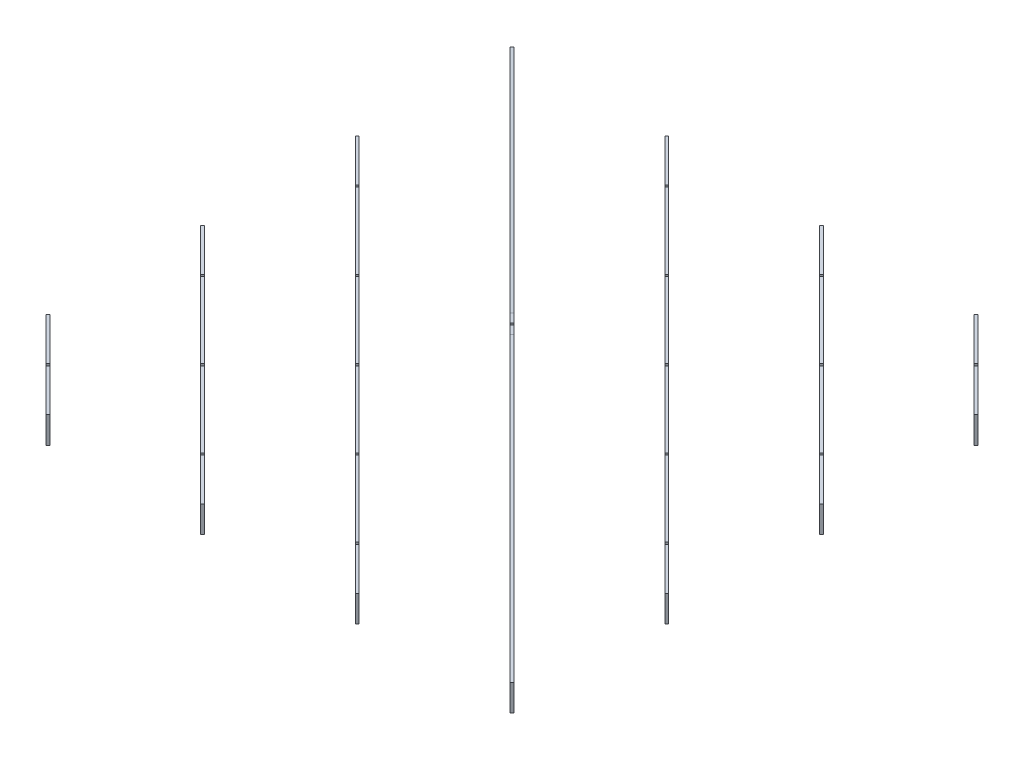
from build123d import *

# Parameters (mm, degrees)
BOSS_EXTRUDE1_DEPTH   = 60
BOSS_EXTRUDE1_2_DEPTH = 60
BOSS_EXTRUDE1_3_DEPTH = 60
BOSS_EXTRUDE1_4_DEPTH = 60
BOSS_EXTRUDE1_5_DEPTH = 60
BOSS_EXTRUDE1_6_DEPTH = 60
BOSS_EXTRUDE1_7_DEPTH = 60
BOSS_EXTRUDE2_START   = -6
BOSS_EXTRUDE2_DEPTH   = 6
SKETCH5_R             = 1.5
SKETCH5_W             = 6
SKETCH5_H             = 60
CUT_EXTRUDE1_DEPTH    = 500.974747
SKETCH6_R             = 1.5
SKETCH6_W             = 6
SKETCH6_H             = 60
CUT_EXTRUDE2_DEPTH    = 500.974747
CUT_EXTRUDE3_DEPTH    = 6


with BuildPart() as part:
    # Sketch2 → Boss-Extrude1 (new body)
    with BuildSketch(Plane(origin=(0, 0, 0), x_dir=(1, 0, 0), z_dir=(0, 1, 0))):
        Polygon((-625, -429.242640687), (-429.242640687, -625), (-425, -620.757359313), (-620.757359313, -425), align=None)
    extrude(amount=BOSS_EXTRUDE1_DEPTH)


with BuildPart() as body_2:
    # Sketch2 → Boss-Extrude1 2 (new body)
    with BuildSketch(Plane(origin=(0, 0, 0), x_dir=(1, 0, 0), z_dir=(0, 1, 0))):
        Polygon((-625, -79.242640687), (-79.242640687, -625), (-75, -620.757359313), (-620.757359313, -75), align=None)
    extrude(amount=BOSS_EXTRUDE1_2_DEPTH)


with BuildPart() as body_3:
    # Sketch2 → Boss-Extrude1 3 (new body)
    with BuildSketch(Plane(origin=(0, 0, 0), x_dir=(1, 0, 0), z_dir=(0, 1, 0))):
        Polygon((-625, 270.757359313), (270.757359313, -625), (275, -620.757359313), (-620.757359313, 275), align=None)
    extrude(amount=BOSS_EXTRUDE1_3_DEPTH)


with BuildPart() as body_4:
    # Sketch2 → Boss-Extrude1 4 (new body)
    with BuildSketch(Plane(origin=(0, 0, 0), x_dir=(1, 0, 0), z_dir=(0, 1, 0))):
        Polygon((625, -620.757359313), (-620.757359313, 625), (-625, 620.757359313), (620.757359313, -625), align=None)
    extrude(amount=BOSS_EXTRUDE1_4_DEPTH)

    # Sketch4 → Boss-Extrude2 (add)
    with BuildSketch(Plane(origin=(-2.121320344, 0, 2.121320344), x_dir=(0.707106781, 0, 0.707106781), z_dir=(-0.707106781, 0, 0.707106781)).offset(BOSS_EXTRUDE2_START)):
        Polygon((-30, 140), (-880.883476483, 60), (-30, 60), (30, 60), (880.883476483, 60), (30, 140), align=None)
    extrude(amount=BOSS_EXTRUDE2_DEPTH)

    # Sketch7 → Cut-Extrude3 (cut)
    with BuildSketch(Plane(origin=(-2.121320344, 0, 2.121320344), x_dir=(0.707106781, 0, 0.707106781), z_dir=(-0.707106781, 0, 0.707106781))):
        with BuildLine():
            ThreePointArc((-743.962120246, 30), (-746.522780418, 31.060660172), (-745.462120246, 28.5))
            Line((-745.462120246, 28.5), (-745.462120246, 30))
            Line((-745.462120246, 30), (-743.962120246, 30))
        make_face()
        with BuildLine():
            Line((-745.462120246, 30), (-745.462120246, 28.5))
            ThreePointArc((-745.462120246, 28.5), (-744.401460074, 28.939339828), (-743.962120246, 30))
            Line((-743.962120246, 30), (-745.462120246, 30))
        make_face()
        with BuildLine():
            ThreePointArc((-743.962120246, 30), (-746.522780418, 31.060660172), (-745.462120246, 28.5))
            Line((-745.462120246, 28.5), (-745.462120246, 30))
            Line((-745.462120246, 30), (-743.962120246, 30))
        make_face()
        with BuildLine():
            Line((-745.462120246, 30), (-745.462120246, 28.5))
            ThreePointArc((-745.462120246, 28.5), (-744.401460074, 28.939339828), (-743.962120246, 30))
            Line((-743.962120246, 30), (-745.462120246, 30))
        make_face()
        with BuildLine():
            Line((-745.462120246, 0), (-739.462120246, 0))
            Line((-739.462120246, 0), (-739.462120246, 28.5))
            ThreePointArc((-739.462120246, 28.5), (-740.522780418, 28.939339828), (-740.962120246, 30))
            Line((-740.962120246, 30), (-743.962120246, 30))
            ThreePointArc((-743.962120246, 30), (-744.401460074, 28.939339828), (-745.462120246, 28.5))
            Line((-745.462120246, 28.5), (-745.462120246, 0))
        make_face()
        with BuildLine():
            ThreePointArc((-740.962120246, 30), (-740.522780418, 28.939339828), (-739.462120246, 28.5))
            Line((-739.462120246, 28.5), (-739.462120246, 30))
            Line((-739.462120246, 30), (-740.962120246, 30))
        make_face()
        with BuildLine():
            Line((-739.462120246, 30), (-739.462120246, 28.5))
            ThreePointArc((-739.462120246, 28.5), (-738.401460074, 28.939339828), (-737.962120246, 30))
            ThreePointArc((-737.962120246, 30), (-739.462120246, 31.5), (-740.962120246, 30))
            Line((-740.962120246, 30), (-739.462120246, 30))
        make_face()
        with BuildLine():
            ThreePointArc((-740.962120246, 30), (-740.522780418, 28.939339828), (-739.462120246, 28.5))
            Line((-739.462120246, 28.5), (-739.462120246, 30))
            Line((-739.462120246, 30), (-740.962120246, 30))
        make_face()
        with BuildLine():
            Line((-739.462120246, 30), (-739.462120246, 28.5))
            ThreePointArc((-739.462120246, 28.5), (-738.401460074, 28.939339828), (-737.962120246, 30))
            ThreePointArc((-737.962120246, 30), (-739.462120246, 31.5), (-740.962120246, 30))
            Line((-740.962120246, 30), (-739.462120246, 30))
        make_face()
        with BuildLine():
            ThreePointArc((-496.474746831, 30), (-499.035407002, 31.060660172), (-497.974746831, 28.5))
            Line((-497.974746831, 28.5), (-497.974746831, 30))
            Line((-497.974746831, 30), (-496.474746831, 30))
        make_face()
        with BuildLine():
            Line((-497.974746831, 30), (-497.974746831, 28.5))
            ThreePointArc((-497.974746831, 28.5), (-496.914086659, 28.939339828), (-496.474746831, 30))
            Line((-496.474746831, 30), (-497.974746831, 30))
        make_face()
        with BuildLine():
            ThreePointArc((-496.474746831, 30), (-499.035407002, 31.060660172), (-497.974746831, 28.5))
            Line((-497.974746831, 28.5), (-497.974746831, 30))
            Line((-497.974746831, 30), (-496.474746831, 30))
        make_face()
        with BuildLine():
            Line((-497.974746831, 30), (-497.974746831, 28.5))
            ThreePointArc((-497.974746831, 28.5), (-496.914086659, 28.939339828), (-496.474746831, 30))
            Line((-496.474746831, 30), (-497.974746831, 30))
        make_face()
        with BuildLine():
            Line((-497.974746831, 0), (-491.974746831, 0))
            Line((-491.974746831, 0), (-491.974746831, 28.5))
            ThreePointArc((-491.974746831, 28.5), (-493.035407002, 28.939339828), (-493.474746831, 30))
            Line((-493.474746831, 30), (-496.474746831, 30))
            ThreePointArc((-496.474746831, 30), (-496.914086659, 28.939339828), (-497.974746831, 28.5))
            Line((-497.974746831, 28.5), (-497.974746831, 0))
        make_face()
        with BuildLine():
            ThreePointArc((-493.474746831, 30), (-493.035407002, 28.939339828), (-491.974746831, 28.5))
            Line((-491.974746831, 28.5), (-491.974746831, 30))
            Line((-491.974746831, 30), (-493.474746831, 30))
        make_face()
        with BuildLine():
            Line((-491.974746831, 30), (-491.974746831, 28.5))
            ThreePointArc((-491.974746831, 28.5), (-490.914086659, 28.939339828), (-490.474746831, 30))
            ThreePointArc((-490.474746831, 30), (-491.974746831, 31.5), (-493.474746831, 30))
            Line((-493.474746831, 30), (-491.974746831, 30))
        make_face()
        with BuildLine():
            ThreePointArc((-493.474746831, 30), (-493.035407002, 28.939339828), (-491.974746831, 28.5))
            Line((-491.974746831, 28.5), (-491.974746831, 30))
            Line((-491.974746831, 30), (-493.474746831, 30))
        make_face()
        with BuildLine():
            Line((-491.974746831, 30), (-491.974746831, 28.5))
            ThreePointArc((-491.974746831, 28.5), (-490.914086659, 28.939339828), (-490.474746831, 30))
            ThreePointArc((-490.474746831, 30), (-491.974746831, 31.5), (-493.474746831, 30))
            Line((-493.474746831, 30), (-491.974746831, 30))
        make_face()
        with BuildLine():
            ThreePointArc((-242.987373415, 30), (-244.487373415, 31.5), (-245.987373415, 30))
            Line((-245.987373415, 30), (-244.487373415, 30))
            Line((-244.487373415, 30), (-244.487373415, 28.5))
            ThreePointArc((-244.487373415, 28.5), (-243.426713244, 28.939339828), (-242.987373415, 30))
        make_face()
        with BuildLine():
            Line((-244.487373415, 30), (-245.987373415, 30))
            ThreePointArc((-245.987373415, 30), (-245.548033587, 28.939339828), (-244.487373415, 28.5))
            Line((-244.487373415, 28.5), (-244.487373415, 30))
        make_face()
        with BuildLine():
            ThreePointArc((-242.987373415, 30), (-244.487373415, 31.5), (-245.987373415, 30))
            Line((-245.987373415, 30), (-244.487373415, 30))
            Line((-244.487373415, 30), (-244.487373415, 28.5))
            ThreePointArc((-244.487373415, 28.5), (-243.426713244, 28.939339828), (-242.987373415, 30))
        make_face()
        with BuildLine():
            Line((-244.487373415, 30), (-245.987373415, 30))
            ThreePointArc((-245.987373415, 30), (-245.548033587, 28.939339828), (-244.487373415, 28.5))
            Line((-244.487373415, 28.5), (-244.487373415, 30))
        make_face()
        with BuildLine():
            Line((-245.987373415, 30), (-248.987373415, 30))
            ThreePointArc((-248.987373415, 30), (-249.426713244, 28.939339828), (-250.487373415, 28.5))
            Line((-250.487373415, 28.5), (-250.487373415, 0))
            Line((-250.487373415, 0), (-244.487373415, 0))
            Line((-244.487373415, 0), (-244.487373415, 28.5))
            ThreePointArc((-244.487373415, 28.5), (-245.548033587, 28.939339828), (-245.987373415, 30))
        make_face()
        with BuildLine():
            Line((-250.487373415, 28.5), (-250.487373415, 30))
            Line((-250.487373415, 30), (-248.987373415, 30))
            ThreePointArc((-248.987373415, 30), (-251.548033587, 31.060660172), (-250.487373415, 28.5))
        make_face()
        with BuildLine():
            Line((-248.987373415, 30), (-250.487373415, 30))
            Line((-250.487373415, 30), (-250.487373415, 28.5))
            ThreePointArc((-250.487373415, 28.5), (-249.426713244, 28.939339828), (-248.987373415, 30))
        make_face()
        with BuildLine():
            Line((-250.487373415, 28.5), (-250.487373415, 30))
            Line((-250.487373415, 30), (-248.987373415, 30))
            ThreePointArc((-248.987373415, 30), (-251.548033587, 31.060660172), (-250.487373415, 28.5))
        make_face()
        with BuildLine():
            Line((-248.987373415, 30), (-250.487373415, 30))
            Line((-250.487373415, 30), (-250.487373415, 28.5))
            ThreePointArc((-250.487373415, 28.5), (-249.426713244, 28.939339828), (-248.987373415, 30))
        make_face()
        with BuildLine():
            Line((3, 140), (-3, 140))
            Line((-3, 140), (-3, 71.5))
            ThreePointArc((-3, 71.5), (-1.939339828, 71.060660172), (-1.5, 70))
            Line((-1.5, 70), (1.5, 70))
            ThreePointArc((1.5, 70), (1.939339828, 71.060660172), (3, 71.5))
            Line((3, 71.5), (3, 140))
        make_face()
        with BuildLine():
            ThreePointArc((-1.5, 70), (-1.939339828, 71.060660172), (-3, 71.5))
            Line((-3, 71.5), (-3, 70))
            Line((-3, 70), (-1.5, 70))
        make_face()
        with BuildLine():
            Line((-3, 70), (-3, 71.5))
            ThreePointArc((-3, 71.5), (-4.060660172, 68.939339828), (-1.5, 70))
            Line((-1.5, 70), (-3, 70))
        make_face()
        with BuildLine():
            ThreePointArc((-1.5, 70), (-1.939339828, 71.060660172), (-3, 71.5))
            Line((-3, 71.5), (-3, 70))
            Line((-3, 70), (-1.5, 70))
        make_face()
        with BuildLine():
            Line((-3, 70), (-3, 71.5))
            ThreePointArc((-3, 71.5), (-4.060660172, 68.939339828), (-1.5, 70))
            Line((-1.5, 70), (-3, 70))
        make_face()
        with BuildLine():
            ThreePointArc((4.5, 70), (4.060660172, 71.060660172), (3, 71.5))
            Line((3, 71.5), (3, 70))
            Line((3, 70), (1.5, 70))
            ThreePointArc((1.5, 70), (3, 68.5), (4.5, 70))
        make_face()
        with BuildLine():
            Line((3, 70), (3, 71.5))
            ThreePointArc((3, 71.5), (1.939339828, 71.060660172), (1.5, 70))
            Line((1.5, 70), (3, 70))
        make_face()
        with BuildLine():
            ThreePointArc((4.5, 70), (4.060660172, 71.060660172), (3, 71.5))
            Line((3, 71.5), (3, 70))
            Line((3, 70), (1.5, 70))
            ThreePointArc((1.5, 70), (3, 68.5), (4.5, 70))
        make_face()
        with BuildLine():
            Line((3, 70), (3, 71.5))
            ThreePointArc((3, 71.5), (1.939339828, 71.060660172), (1.5, 70))
            Line((1.5, 70), (3, 70))
        make_face()
        with BuildLine():
            ThreePointArc((245.987373415, 30), (243.426713244, 31.060660172), (244.487373415, 28.5))
            Line((244.487373415, 28.5), (244.487373415, 30))
            Line((244.487373415, 30), (245.987373415, 30))
        make_face()
        with BuildLine():
            Line((244.487373415, 30), (244.487373415, 28.5))
            ThreePointArc((244.487373415, 28.5), (245.548033587, 28.939339828), (245.987373415, 30))
            Line((245.987373415, 30), (244.487373415, 30))
        make_face()
        with BuildLine():
            ThreePointArc((245.987373415, 30), (243.426713244, 31.060660172), (244.487373415, 28.5))
            Line((244.487373415, 28.5), (244.487373415, 30))
            Line((244.487373415, 30), (245.987373415, 30))
        make_face()
        with BuildLine():
            Line((244.487373415, 30), (244.487373415, 28.5))
            ThreePointArc((244.487373415, 28.5), (245.548033587, 28.939339828), (245.987373415, 30))
            Line((245.987373415, 30), (244.487373415, 30))
        make_face()
        with BuildLine():
            Line((244.487373415, 28.5), (244.487373415, 0))
            Line((244.487373415, 0), (250.487373415, 0))
            Line((250.487373415, 0), (250.487373415, 28.5))
            ThreePointArc((250.487373415, 28.5), (249.426713244, 28.939339828), (248.987373415, 30))
            Line((248.987373415, 30), (245.987373415, 30))
            ThreePointArc((245.987373415, 30), (245.548033587, 28.939339828), (244.487373415, 28.5))
        make_face()
        with BuildLine():
            ThreePointArc((248.987373415, 30), (249.426713244, 28.939339828), (250.487373415, 28.5))
            Line((250.487373415, 28.5), (250.487373415, 30))
            Line((250.487373415, 30), (248.987373415, 30))
        make_face()
        with BuildLine():
            Line((250.487373415, 30), (250.487373415, 28.5))
            ThreePointArc((250.487373415, 28.5), (251.548033587, 28.939339828), (251.987373415, 30))
            ThreePointArc((251.987373415, 30), (250.487373415, 31.5), (248.987373415, 30))
            Line((248.987373415, 30), (250.487373415, 30))
        make_face()
        with BuildLine():
            ThreePointArc((248.987373415, 30), (249.426713244, 28.939339828), (250.487373415, 28.5))
            Line((250.487373415, 28.5), (250.487373415, 30))
            Line((250.487373415, 30), (248.987373415, 30))
        make_face()
        with BuildLine():
            Line((250.487373415, 30), (250.487373415, 28.5))
            ThreePointArc((250.487373415, 28.5), (251.548033587, 28.939339828), (251.987373415, 30))
            ThreePointArc((251.987373415, 30), (250.487373415, 31.5), (248.987373415, 30))
            Line((248.987373415, 30), (250.487373415, 30))
        make_face()
        with BuildLine():
            ThreePointArc((493.474746831, 30), (490.914086659, 31.060660172), (491.974746831, 28.5))
            Line((491.974746831, 28.5), (491.974746831, 30))
            Line((491.974746831, 30), (493.474746831, 30))
        make_face()
        with BuildLine():
            Line((491.974746831, 30), (491.974746831, 28.5))
            ThreePointArc((491.974746831, 28.5), (493.035407002, 28.939339828), (493.474746831, 30))
            Line((493.474746831, 30), (491.974746831, 30))
        make_face()
        with BuildLine():
            ThreePointArc((493.474746831, 30), (490.914086659, 31.060660172), (491.974746831, 28.5))
            Line((491.974746831, 28.5), (491.974746831, 30))
            Line((491.974746831, 30), (493.474746831, 30))
        make_face()
        with BuildLine():
            Line((491.974746831, 30), (491.974746831, 28.5))
            ThreePointArc((491.974746831, 28.5), (493.035407002, 28.939339828), (493.474746831, 30))
            Line((493.474746831, 30), (491.974746831, 30))
        make_face()
        with BuildLine():
            Line((491.974746831, 28.5), (491.974746831, 0))
            Line((491.974746831, 0), (497.974746831, 0))
            Line((497.974746831, 0), (497.974746831, 28.5))
            ThreePointArc((497.974746831, 28.5), (496.914086659, 28.939339828), (496.474746831, 30))
            Line((496.474746831, 30), (493.474746831, 30))
            ThreePointArc((493.474746831, 30), (493.035407002, 28.939339828), (491.974746831, 28.5))
        make_face()
        with BuildLine():
            ThreePointArc((496.474746831, 30), (496.914086659, 28.939339828), (497.974746831, 28.5))
            Line((497.974746831, 28.5), (497.974746831, 30))
            Line((497.974746831, 30), (496.474746831, 30))
        make_face()
        with BuildLine():
            Line((497.974746831, 30), (497.974746831, 28.5))
            ThreePointArc((497.974746831, 28.5), (499.035407002, 28.939339828), (499.474746831, 30))
            ThreePointArc((499.474746831, 30), (497.974746831, 31.5), (496.474746831, 30))
            Line((496.474746831, 30), (497.974746831, 30))
        make_face()
        with BuildLine():
            ThreePointArc((496.474746831, 30), (496.914086659, 28.939339828), (497.974746831, 28.5))
            Line((497.974746831, 28.5), (497.974746831, 30))
            Line((497.974746831, 30), (496.474746831, 30))
        make_face()
        with BuildLine():
            Line((497.974746831, 30), (497.974746831, 28.5))
            ThreePointArc((497.974746831, 28.5), (499.035407002, 28.939339828), (499.474746831, 30))
            ThreePointArc((499.474746831, 30), (497.974746831, 31.5), (496.474746831, 30))
            Line((496.474746831, 30), (497.974746831, 30))
        make_face()
        with BuildLine():
            ThreePointArc((740.962120246, 30), (738.401460074, 31.060660172), (739.462120246, 28.5))
            Line((739.462120246, 28.5), (739.462120246, 30))
            Line((739.462120246, 30), (740.962120246, 30))
        make_face()
        with BuildLine():
            Line((739.462120246, 30), (739.462120246, 28.5))
            ThreePointArc((739.462120246, 28.5), (740.522780418, 28.939339828), (740.962120246, 30))
            Line((740.962120246, 30), (739.462120246, 30))
        make_face()
        with BuildLine():
            ThreePointArc((740.962120246, 30), (738.401460074, 31.060660172), (739.462120246, 28.5))
            Line((739.462120246, 28.5), (739.462120246, 30))
            Line((739.462120246, 30), (740.962120246, 30))
        make_face()
        with BuildLine():
            Line((739.462120246, 30), (739.462120246, 28.5))
            ThreePointArc((739.462120246, 28.5), (740.522780418, 28.939339828), (740.962120246, 30))
            Line((740.962120246, 30), (739.462120246, 30))
        make_face()
        with BuildLine():
            Line((739.462120246, 28.5), (739.462120246, 0))
            Line((739.462120246, 0), (745.462120246, 0))
            Line((745.462120246, 0), (745.462120246, 28.5))
            ThreePointArc((745.462120246, 28.5), (744.401460074, 28.939339828), (743.962120246, 30))
            Line((743.962120246, 30), (740.962120246, 30))
            ThreePointArc((740.962120246, 30), (740.522780418, 28.939339828), (739.462120246, 28.5))
        make_face()
        with BuildLine():
            ThreePointArc((743.962120246, 30), (744.401460074, 28.939339828), (745.462120246, 28.5))
            Line((745.462120246, 28.5), (745.462120246, 30))
            Line((745.462120246, 30), (743.962120246, 30))
        make_face()
        with BuildLine():
            Line((745.462120246, 30), (745.462120246, 28.5))
            ThreePointArc((745.462120246, 28.5), (746.522780418, 28.939339828), (746.962120246, 30))
            ThreePointArc((746.962120246, 30), (745.462120246, 31.5), (743.962120246, 30))
            Line((743.962120246, 30), (745.462120246, 30))
        make_face()
        with BuildLine():
            ThreePointArc((743.962120246, 30), (744.401460074, 28.939339828), (745.462120246, 28.5))
            Line((745.462120246, 28.5), (745.462120246, 30))
            Line((745.462120246, 30), (743.962120246, 30))
        make_face()
        with BuildLine():
            Line((745.462120246, 30), (745.462120246, 28.5))
            ThreePointArc((745.462120246, 28.5), (746.522780418, 28.939339828), (746.962120246, 30))
            ThreePointArc((746.962120246, 30), (745.462120246, 31.5), (743.962120246, 30))
            Line((743.962120246, 30), (745.462120246, 30))
        make_face()
    extrude(amount=-CUT_EXTRUDE3_DEPTH, mode=Mode.SUBTRACT)


with BuildPart() as body_5:
    # Sketch2 → Boss-Extrude1 5 (new body)
    with BuildSketch(Plane(origin=(0, 0, 0), x_dir=(1, 0, 0), z_dir=(0, 1, 0))):
        Polygon((-275, 620.757359313), (620.757359313, -275), (625, -270.757359313), (-270.757359313, 625), align=None)
    extrude(amount=BOSS_EXTRUDE1_5_DEPTH)


with BuildPart() as body_6:
    # Sketch2 → Boss-Extrude1 6 (new body)
    with BuildSketch(Plane(origin=(0, 0, 0), x_dir=(1, 0, 0), z_dir=(0, 1, 0))):
        Polygon((75, 620.757359313), (620.757359313, 75), (625, 79.242640687), (79.242640687, 625), align=None)
    extrude(amount=BOSS_EXTRUDE1_6_DEPTH)


with BuildPart() as body_7:
    # Sketch2 → Boss-Extrude1 7 (new body)
    with BuildSketch(Plane(origin=(0, 0, 0), x_dir=(1, 0, 0), z_dir=(0, 1, 0))):
        Polygon((425, 620.757359313), (620.757359313, 425), (625, 429.242640687), (429.242640687, 625), align=None)
    extrude(amount=BOSS_EXTRUDE1_7_DEPTH)


with BuildPart() as cut_extrude1_tool:
    # Sketch5 → Cut-Extrude1 (new body)
    with BuildSketch(Plane(origin=(-527.121320344, 0, 527.121320344), x_dir=(0.707106781, 0, 0.707106781), z_dir=(-0.707106781, 0, 0.707106781))):
        with Locations((497.974746831, 30)):
            Circle(SKETCH5_R)
        with Locations((491.974746831, 30)):
            Circle(SKETCH5_R)
        with Locations((494.974746831, 60)):
            Rectangle(SKETCH5_W, SKETCH5_H)
        with BuildLine():
            ThreePointArc((493.474746831, 30), (493.035407002, 31.060660172), (491.974746831, 31.5))
            Line((491.974746831, 31.5), (491.974746831, 30))
            Line((491.974746831, 30), (493.474746831, 30))
        make_face()
        with BuildLine():
            Line((491.974746831, 30), (491.974746831, 31.5))
            ThreePointArc((491.974746831, 31.5), (490.914086659, 28.939339828), (493.474746831, 30))
            Line((493.474746831, 30), (491.974746831, 30))
        make_face()
        with BuildLine():
            ThreePointArc((493.474746831, 30), (493.035407002, 31.060660172), (491.974746831, 31.5))
            Line((491.974746831, 31.5), (491.974746831, 30))
            Line((491.974746831, 30), (493.474746831, 30))
        make_face()
        with BuildLine():
            Line((491.974746831, 30), (491.974746831, 31.5))
            ThreePointArc((491.974746831, 31.5), (490.914086659, 28.939339828), (493.474746831, 30))
            Line((493.474746831, 30), (491.974746831, 30))
        make_face()
        with BuildLine():
            ThreePointArc((499.474746831, 30), (499.035407002, 31.060660172), (497.974746831, 31.5))
            Line((497.974746831, 31.5), (497.974746831, 30))
            Line((497.974746831, 30), (496.474746831, 30))
            ThreePointArc((496.474746831, 30), (497.974746831, 28.5), (499.474746831, 30))
        make_face()
        with BuildLine():
            Line((497.974746831, 30), (497.974746831, 31.5))
            ThreePointArc((497.974746831, 31.5), (496.914086659, 31.060660172), (496.474746831, 30))
            Line((496.474746831, 30), (497.974746831, 30))
        make_face()
        with BuildLine():
            ThreePointArc((499.474746831, 30), (499.035407002, 31.060660172), (497.974746831, 31.5))
            Line((497.974746831, 31.5), (497.974746831, 30))
            Line((497.974746831, 30), (496.474746831, 30))
            ThreePointArc((496.474746831, 30), (497.974746831, 28.5), (499.474746831, 30))
        make_face()
        with BuildLine():
            Line((497.974746831, 30), (497.974746831, 31.5))
            ThreePointArc((497.974746831, 31.5), (496.914086659, 31.060660172), (496.474746831, 30))
            Line((496.474746831, 30), (497.974746831, 30))
        make_face()
        with Locations((250.487373415, 30)):
            Circle(SKETCH5_R)
        with Locations((244.487373415, 30)):
            Circle(SKETCH5_R)
        with Locations((247.487373415, 60)):
            Rectangle(SKETCH5_W, SKETCH5_H)
        with BuildLine():
            ThreePointArc((245.987373415, 30), (245.548033587, 31.060660172), (244.487373415, 31.5))
            Line((244.487373415, 31.5), (244.487373415, 30))
            Line((244.487373415, 30), (245.987373415, 30))
        make_face()
        with BuildLine():
            Line((244.487373415, 30), (244.487373415, 31.5))
            ThreePointArc((244.487373415, 31.5), (243.426713244, 28.939339828), (245.987373415, 30))
            Line((245.987373415, 30), (244.487373415, 30))
        make_face()
        with BuildLine():
            ThreePointArc((245.987373415, 30), (245.548033587, 31.060660172), (244.487373415, 31.5))
            Line((244.487373415, 31.5), (244.487373415, 30))
            Line((244.487373415, 30), (245.987373415, 30))
        make_face()
        with BuildLine():
            Line((244.487373415, 30), (244.487373415, 31.5))
            ThreePointArc((244.487373415, 31.5), (243.426713244, 28.939339828), (245.987373415, 30))
            Line((245.987373415, 30), (244.487373415, 30))
        make_face()
        with BuildLine():
            ThreePointArc((251.987373415, 30), (251.548033587, 31.060660172), (250.487373415, 31.5))
            Line((250.487373415, 31.5), (250.487373415, 30))
            Line((250.487373415, 30), (248.987373415, 30))
            ThreePointArc((248.987373415, 30), (250.487373415, 28.5), (251.987373415, 30))
        make_face()
        with BuildLine():
            Line((250.487373415, 30), (250.487373415, 31.5))
            ThreePointArc((250.487373415, 31.5), (249.426713244, 31.060660172), (248.987373415, 30))
            Line((248.987373415, 30), (250.487373415, 30))
        make_face()
        with BuildLine():
            ThreePointArc((251.987373415, 30), (251.548033587, 31.060660172), (250.487373415, 31.5))
            Line((250.487373415, 31.5), (250.487373415, 30))
            Line((250.487373415, 30), (248.987373415, 30))
            ThreePointArc((248.987373415, 30), (250.487373415, 28.5), (251.987373415, 30))
        make_face()
        with BuildLine():
            Line((250.487373415, 30), (250.487373415, 31.5))
            ThreePointArc((250.487373415, 31.5), (249.426713244, 31.060660172), (248.987373415, 30))
            Line((248.987373415, 30), (250.487373415, 30))
        make_face()
        with BuildLine():
            Line((3, 60), (-3, 60))
            Line((-3, 60), (-3, 31.5))
            ThreePointArc((-3, 31.5), (-1.939339828, 31.060660172), (-1.5, 30))
            Line((-1.5, 30), (1.5, 30))
            ThreePointArc((1.5, 30), (1.939339828, 31.060660172), (3, 31.5))
            Line((3, 31.5), (3, 60))
        make_face()
        with BuildLine():
            ThreePointArc((-1.5, 30), (-1.939339828, 31.060660172), (-3, 31.5))
            Line((-3, 31.5), (-3, 30))
            Line((-3, 30), (-1.5, 30))
        make_face()
        with BuildLine():
            Line((-3, 30), (-3, 31.5))
            ThreePointArc((-3, 31.5), (-4.060660172, 28.939339828), (-1.5, 30))
            Line((-1.5, 30), (-3, 30))
        make_face()
        with BuildLine():
            ThreePointArc((-1.5, 30), (-1.939339828, 31.060660172), (-3, 31.5))
            Line((-3, 31.5), (-3, 30))
            Line((-3, 30), (-1.5, 30))
        make_face()
        with BuildLine():
            Line((-3, 30), (-3, 31.5))
            ThreePointArc((-3, 31.5), (-4.060660172, 28.939339828), (-1.5, 30))
            Line((-1.5, 30), (-3, 30))
        make_face()
        with BuildLine():
            ThreePointArc((4.5, 30), (4.060660172, 31.060660172), (3, 31.5))
            Line((3, 31.5), (3, 30))
            Line((3, 30), (1.5, 30))
            ThreePointArc((1.5, 30), (3, 28.5), (4.5, 30))
        make_face()
        with BuildLine():
            Line((3, 30), (3, 31.5))
            ThreePointArc((3, 31.5), (1.939339828, 31.060660172), (1.5, 30))
            Line((1.5, 30), (3, 30))
        make_face()
        with BuildLine():
            ThreePointArc((4.5, 30), (4.060660172, 31.060660172), (3, 31.5))
            Line((3, 31.5), (3, 30))
            Line((3, 30), (1.5, 30))
            ThreePointArc((1.5, 30), (3, 28.5), (4.5, 30))
        make_face()
        with BuildLine():
            Line((3, 30), (3, 31.5))
            ThreePointArc((3, 31.5), (1.939339828, 31.060660172), (1.5, 30))
            Line((1.5, 30), (3, 30))
        make_face()
        with Locations((-244.487373415, 30)):
            Circle(SKETCH5_R)
        with Locations((-250.487373415, 30)):
            Circle(SKETCH5_R)
        with Locations((-247.487373415, 60)):
            Rectangle(SKETCH5_W, SKETCH5_H)
        with BuildLine():
            ThreePointArc((-248.987373415, 30), (-249.426713244, 31.060660172), (-250.487373415, 31.5))
            Line((-250.487373415, 31.5), (-250.487373415, 30))
            Line((-250.487373415, 30), (-248.987373415, 30))
        make_face()
        with BuildLine():
            Line((-250.487373415, 30), (-250.487373415, 31.5))
            ThreePointArc((-250.487373415, 31.5), (-251.548033587, 28.939339828), (-248.987373415, 30))
            Line((-248.987373415, 30), (-250.487373415, 30))
        make_face()
        with BuildLine():
            ThreePointArc((-248.987373415, 30), (-249.426713244, 31.060660172), (-250.487373415, 31.5))
            Line((-250.487373415, 31.5), (-250.487373415, 30))
            Line((-250.487373415, 30), (-248.987373415, 30))
        make_face()
        with BuildLine():
            Line((-250.487373415, 30), (-250.487373415, 31.5))
            ThreePointArc((-250.487373415, 31.5), (-251.548033587, 28.939339828), (-248.987373415, 30))
            Line((-248.987373415, 30), (-250.487373415, 30))
        make_face()
        with BuildLine():
            ThreePointArc((-242.987373415, 30), (-243.426713244, 31.060660172), (-244.487373415, 31.5))
            Line((-244.487373415, 31.5), (-244.487373415, 30))
            Line((-244.487373415, 30), (-245.987373415, 30))
            ThreePointArc((-245.987373415, 30), (-244.487373415, 28.5), (-242.987373415, 30))
        make_face()
        with BuildLine():
            Line((-244.487373415, 30), (-244.487373415, 31.5))
            ThreePointArc((-244.487373415, 31.5), (-245.548033587, 31.060660172), (-245.987373415, 30))
            Line((-245.987373415, 30), (-244.487373415, 30))
        make_face()
        with BuildLine():
            ThreePointArc((-242.987373415, 30), (-243.426713244, 31.060660172), (-244.487373415, 31.5))
            Line((-244.487373415, 31.5), (-244.487373415, 30))
            Line((-244.487373415, 30), (-245.987373415, 30))
            ThreePointArc((-245.987373415, 30), (-244.487373415, 28.5), (-242.987373415, 30))
        make_face()
        with BuildLine():
            Line((-244.487373415, 30), (-244.487373415, 31.5))
            ThreePointArc((-244.487373415, 31.5), (-245.548033587, 31.060660172), (-245.987373415, 30))
            Line((-245.987373415, 30), (-244.487373415, 30))
        make_face()
        with Locations((-491.974746831, 30)):
            Circle(SKETCH5_R)
        with Locations((-497.974746831, 30)):
            Circle(SKETCH5_R)
        with Locations((-494.974746831, 60)):
            Rectangle(SKETCH5_W, SKETCH5_H)
        with BuildLine():
            ThreePointArc((-496.474746831, 30), (-496.914086659, 31.060660172), (-497.974746831, 31.5))
            Line((-497.974746831, 31.5), (-497.974746831, 30))
            Line((-497.974746831, 30), (-496.474746831, 30))
        make_face()
        with BuildLine():
            Line((-497.974746831, 30), (-497.974746831, 31.5))
            ThreePointArc((-497.974746831, 31.5), (-499.035407002, 28.939339828), (-496.474746831, 30))
            Line((-496.474746831, 30), (-497.974746831, 30))
        make_face()
        with BuildLine():
            ThreePointArc((-496.474746831, 30), (-496.914086659, 31.060660172), (-497.974746831, 31.5))
            Line((-497.974746831, 31.5), (-497.974746831, 30))
            Line((-497.974746831, 30), (-496.474746831, 30))
        make_face()
        with BuildLine():
            Line((-497.974746831, 30), (-497.974746831, 31.5))
            ThreePointArc((-497.974746831, 31.5), (-499.035407002, 28.939339828), (-496.474746831, 30))
            Line((-496.474746831, 30), (-497.974746831, 30))
        make_face()
        with BuildLine():
            ThreePointArc((-490.474746831, 30), (-490.914086659, 31.060660172), (-491.974746831, 31.5))
            Line((-491.974746831, 31.5), (-491.974746831, 30))
            Line((-491.974746831, 30), (-493.474746831, 30))
            ThreePointArc((-493.474746831, 30), (-491.974746831, 28.5), (-490.474746831, 30))
        make_face()
        with BuildLine():
            Line((-491.974746831, 30), (-491.974746831, 31.5))
            ThreePointArc((-491.974746831, 31.5), (-493.035407002, 31.060660172), (-493.474746831, 30))
            Line((-493.474746831, 30), (-491.974746831, 30))
        make_face()
        with BuildLine():
            ThreePointArc((-490.474746831, 30), (-490.914086659, 31.060660172), (-491.974746831, 31.5))
            Line((-491.974746831, 31.5), (-491.974746831, 30))
            Line((-491.974746831, 30), (-493.474746831, 30))
            ThreePointArc((-493.474746831, 30), (-491.974746831, 28.5), (-490.474746831, 30))
        make_face()
        with BuildLine():
            Line((-491.974746831, 30), (-491.974746831, 31.5))
            ThreePointArc((-491.974746831, 31.5), (-493.035407002, 31.060660172), (-493.474746831, 30))
            Line((-493.474746831, 30), (-491.974746831, 30))
        make_face()
    extrude(amount=-CUT_EXTRUDE1_DEPTH)


with BuildPart() as part_1:
    add(part.part)

    # Cut-Extrude1: cut by cut_extrude1_tool
    add(cut_extrude1_tool.part, mode=Mode.SUBTRACT)


with BuildPart() as body_2_1:
    add(body_2.part)

    # Cut-Extrude1: cut by cut_extrude1_tool
    add(cut_extrude1_tool.part, mode=Mode.SUBTRACT)


with BuildPart() as body_3_1:
    add(body_3.part)

    # Cut-Extrude1: cut by cut_extrude1_tool
    add(cut_extrude1_tool.part, mode=Mode.SUBTRACT)


with BuildPart() as cut_extrude2_tool:
    # Sketch6 → Cut-Extrude2 (new body)
    with BuildSketch(Plane(origin=(527.121320344, 0, -527.121320344), x_dir=(-0.707106781, 0, -0.707106781), z_dir=(0.707106781, 0, -0.707106781))):
        with Locations((-491.974746831, 30)):
            Circle(SKETCH6_R)
        with Locations((-497.974746831, 30)):
            Circle(SKETCH6_R)
        with Locations((-494.974746831, 60)):
            Rectangle(SKETCH6_W, SKETCH6_H)
        with BuildLine():
            ThreePointArc((-497.974746831, 31.5), (-499.035407002, 28.939339828), (-496.474746831, 30))
            Line((-496.474746831, 30), (-497.974746831, 30))
            Line((-497.974746831, 30), (-497.974746831, 31.5))
        make_face()
        with BuildLine():
            Line((-497.974746831, 30), (-496.474746831, 30))
            ThreePointArc((-496.474746831, 30), (-496.914086659, 31.060660172), (-497.974746831, 31.5))
            Line((-497.974746831, 31.5), (-497.974746831, 30))
        make_face()
        with BuildLine():
            ThreePointArc((-497.974746831, 31.5), (-499.035407002, 28.939339828), (-496.474746831, 30))
            Line((-496.474746831, 30), (-497.974746831, 30))
            Line((-497.974746831, 30), (-497.974746831, 31.5))
        make_face()
        with BuildLine():
            Line((-497.974746831, 30), (-496.474746831, 30))
            ThreePointArc((-496.474746831, 30), (-496.914086659, 31.060660172), (-497.974746831, 31.5))
            Line((-497.974746831, 31.5), (-497.974746831, 30))
        make_face()
        with BuildLine():
            Line((-493.474746831, 30), (-491.974746831, 30))
            Line((-491.974746831, 30), (-491.974746831, 31.5))
            ThreePointArc((-491.974746831, 31.5), (-493.035407002, 31.060660172), (-493.474746831, 30))
        make_face()
        with BuildLine():
            Line((-491.974746831, 31.5), (-491.974746831, 30))
            Line((-491.974746831, 30), (-493.474746831, 30))
            ThreePointArc((-493.474746831, 30), (-491.974746831, 28.5), (-490.474746831, 30))
            ThreePointArc((-490.474746831, 30), (-490.914086659, 31.060660172), (-491.974746831, 31.5))
        make_face()
        with BuildLine():
            Line((-493.474746831, 30), (-491.974746831, 30))
            Line((-491.974746831, 30), (-491.974746831, 31.5))
            ThreePointArc((-491.974746831, 31.5), (-493.035407002, 31.060660172), (-493.474746831, 30))
        make_face()
        with BuildLine():
            Line((-491.974746831, 31.5), (-491.974746831, 30))
            Line((-491.974746831, 30), (-493.474746831, 30))
            ThreePointArc((-493.474746831, 30), (-491.974746831, 28.5), (-490.474746831, 30))
            ThreePointArc((-490.474746831, 30), (-490.914086659, 31.060660172), (-491.974746831, 31.5))
        make_face()
        with Locations((-244.487373415, 30)):
            Circle(SKETCH6_R)
        with Locations((-250.487373415, 30)):
            Circle(SKETCH6_R)
        with Locations((-247.487373415, 60)):
            Rectangle(SKETCH6_W, SKETCH6_H)
        with BuildLine():
            ThreePointArc((-250.487373415, 31.5), (-251.548033587, 28.939339828), (-248.987373415, 30))
            Line((-248.987373415, 30), (-250.487373415, 30))
            Line((-250.487373415, 30), (-250.487373415, 31.5))
        make_face()
        with BuildLine():
            Line((-250.487373415, 30), (-248.987373415, 30))
            ThreePointArc((-248.987373415, 30), (-249.426713244, 31.060660172), (-250.487373415, 31.5))
            Line((-250.487373415, 31.5), (-250.487373415, 30))
        make_face()
        with BuildLine():
            ThreePointArc((-250.487373415, 31.5), (-251.548033587, 28.939339828), (-248.987373415, 30))
            Line((-248.987373415, 30), (-250.487373415, 30))
            Line((-250.487373415, 30), (-250.487373415, 31.5))
        make_face()
        with BuildLine():
            Line((-250.487373415, 30), (-248.987373415, 30))
            ThreePointArc((-248.987373415, 30), (-249.426713244, 31.060660172), (-250.487373415, 31.5))
            Line((-250.487373415, 31.5), (-250.487373415, 30))
        make_face()
        with BuildLine():
            Line((-245.987373415, 30), (-244.487373415, 30))
            Line((-244.487373415, 30), (-244.487373415, 31.5))
            ThreePointArc((-244.487373415, 31.5), (-245.548033587, 31.060660172), (-245.987373415, 30))
        make_face()
        with BuildLine():
            Line((-244.487373415, 31.5), (-244.487373415, 30))
            Line((-244.487373415, 30), (-245.987373415, 30))
            ThreePointArc((-245.987373415, 30), (-244.487373415, 28.5), (-242.987373415, 30))
            ThreePointArc((-242.987373415, 30), (-243.426713244, 31.060660172), (-244.487373415, 31.5))
        make_face()
        with BuildLine():
            Line((-245.987373415, 30), (-244.487373415, 30))
            Line((-244.487373415, 30), (-244.487373415, 31.5))
            ThreePointArc((-244.487373415, 31.5), (-245.548033587, 31.060660172), (-245.987373415, 30))
        make_face()
        with BuildLine():
            Line((-244.487373415, 31.5), (-244.487373415, 30))
            Line((-244.487373415, 30), (-245.987373415, 30))
            ThreePointArc((-245.987373415, 30), (-244.487373415, 28.5), (-242.987373415, 30))
            ThreePointArc((-242.987373415, 30), (-243.426713244, 31.060660172), (-244.487373415, 31.5))
        make_face()
        with BuildLine():
            Line((3, 60), (-3, 60))
            Line((-3, 60), (-3, 31.5))
            ThreePointArc((-3, 31.5), (-1.939339828, 31.060660172), (-1.5, 30))
            Line((-1.5, 30), (1.5, 30))
            ThreePointArc((1.5, 30), (1.939339828, 31.060660172), (3, 31.5))
            Line((3, 31.5), (3, 60))
        make_face()
        with BuildLine():
            ThreePointArc((4.5, 30), (4.060660172, 31.060660172), (3, 31.5))
            Line((3, 31.5), (3, 30))
            Line((3, 30), (1.5, 30))
            ThreePointArc((1.5, 30), (3, 28.5), (4.5, 30))
        make_face()
        with BuildLine():
            Line((3, 30), (3, 31.5))
            ThreePointArc((3, 31.5), (1.939339828, 31.060660172), (1.5, 30))
            Line((1.5, 30), (3, 30))
        make_face()
        with BuildLine():
            ThreePointArc((4.5, 30), (4.060660172, 31.060660172), (3, 31.5))
            Line((3, 31.5), (3, 30))
            Line((3, 30), (1.5, 30))
            ThreePointArc((1.5, 30), (3, 28.5), (4.5, 30))
        make_face()
        with BuildLine():
            Line((3, 30), (3, 31.5))
            ThreePointArc((3, 31.5), (1.939339828, 31.060660172), (1.5, 30))
            Line((1.5, 30), (3, 30))
        make_face()
        with BuildLine():
            ThreePointArc((-1.5, 30), (-1.939339828, 31.060660172), (-3, 31.5))
            Line((-3, 31.5), (-3, 30))
            Line((-3, 30), (-1.5, 30))
        make_face()
        with BuildLine():
            Line((-3, 30), (-3, 31.5))
            ThreePointArc((-3, 31.5), (-4.060660172, 28.939339828), (-1.5, 30))
            Line((-1.5, 30), (-3, 30))
        make_face()
        with BuildLine():
            ThreePointArc((-1.5, 30), (-1.939339828, 31.060660172), (-3, 31.5))
            Line((-3, 31.5), (-3, 30))
            Line((-3, 30), (-1.5, 30))
        make_face()
        with BuildLine():
            Line((-3, 30), (-3, 31.5))
            ThreePointArc((-3, 31.5), (-4.060660172, 28.939339828), (-1.5, 30))
            Line((-1.5, 30), (-3, 30))
        make_face()
        with BuildLine():
            ThreePointArc((245.987373415, 30), (245.548033587, 31.060660172), (244.487373415, 31.5))
            Line((244.487373415, 31.5), (244.487373415, 30))
            Line((244.487373415, 30), (245.987373415, 30))
        make_face()
        with BuildLine():
            Line((244.487373415, 30), (244.487373415, 31.5))
            ThreePointArc((244.487373415, 31.5), (243.426713244, 28.939339828), (245.987373415, 30))
            Line((245.987373415, 30), (244.487373415, 30))
        make_face()
        with BuildLine():
            ThreePointArc((245.987373415, 30), (245.548033587, 31.060660172), (244.487373415, 31.5))
            Line((244.487373415, 31.5), (244.487373415, 30))
            Line((244.487373415, 30), (245.987373415, 30))
        make_face()
        with BuildLine():
            Line((244.487373415, 30), (244.487373415, 31.5))
            ThreePointArc((244.487373415, 31.5), (243.426713244, 28.939339828), (245.987373415, 30))
            Line((245.987373415, 30), (244.487373415, 30))
        make_face()
        with Locations((250.487373415, 30)):
            Circle(SKETCH6_R)
        with Locations((244.487373415, 30)):
            Circle(SKETCH6_R)
        with Locations((247.487373415, 60)):
            Rectangle(SKETCH6_W, SKETCH6_H)
        with BuildLine():
            ThreePointArc((251.987373415, 30), (251.548033587, 31.060660172), (250.487373415, 31.5))
            Line((250.487373415, 31.5), (250.487373415, 30))
            Line((250.487373415, 30), (248.987373415, 30))
            ThreePointArc((248.987373415, 30), (250.487373415, 28.5), (251.987373415, 30))
        make_face()
        with BuildLine():
            Line((250.487373415, 30), (250.487373415, 31.5))
            ThreePointArc((250.487373415, 31.5), (249.426713244, 31.060660172), (248.987373415, 30))
            Line((248.987373415, 30), (250.487373415, 30))
        make_face()
        with BuildLine():
            ThreePointArc((251.987373415, 30), (251.548033587, 31.060660172), (250.487373415, 31.5))
            Line((250.487373415, 31.5), (250.487373415, 30))
            Line((250.487373415, 30), (248.987373415, 30))
            ThreePointArc((248.987373415, 30), (250.487373415, 28.5), (251.987373415, 30))
        make_face()
        with BuildLine():
            Line((250.487373415, 30), (250.487373415, 31.5))
            ThreePointArc((250.487373415, 31.5), (249.426713244, 31.060660172), (248.987373415, 30))
            Line((248.987373415, 30), (250.487373415, 30))
        make_face()
        with BuildLine():
            ThreePointArc((493.474746831, 30), (493.035407002, 31.060660172), (491.974746831, 31.5))
            Line((491.974746831, 31.5), (491.974746831, 30))
            Line((491.974746831, 30), (493.474746831, 30))
        make_face()
        with BuildLine():
            Line((491.974746831, 30), (491.974746831, 31.5))
            ThreePointArc((491.974746831, 31.5), (490.914086659, 28.939339828), (493.474746831, 30))
            Line((493.474746831, 30), (491.974746831, 30))
        make_face()
        with BuildLine():
            ThreePointArc((493.474746831, 30), (493.035407002, 31.060660172), (491.974746831, 31.5))
            Line((491.974746831, 31.5), (491.974746831, 30))
            Line((491.974746831, 30), (493.474746831, 30))
        make_face()
        with BuildLine():
            Line((491.974746831, 30), (491.974746831, 31.5))
            ThreePointArc((491.974746831, 31.5), (490.914086659, 28.939339828), (493.474746831, 30))
            Line((493.474746831, 30), (491.974746831, 30))
        make_face()
        with Locations((497.974746831, 30)):
            Circle(SKETCH6_R)
        with Locations((491.974746831, 30)):
            Circle(SKETCH6_R)
        with Locations((494.974746831, 60)):
            Rectangle(SKETCH6_W, SKETCH6_H)
        with BuildLine():
            ThreePointArc((499.474746831, 30), (499.035407002, 31.060660172), (497.974746831, 31.5))
            Line((497.974746831, 31.5), (497.974746831, 30))
            Line((497.974746831, 30), (496.474746831, 30))
            ThreePointArc((496.474746831, 30), (497.974746831, 28.5), (499.474746831, 30))
        make_face()
        with BuildLine():
            Line((497.974746831, 30), (497.974746831, 31.5))
            ThreePointArc((497.974746831, 31.5), (496.914086659, 31.060660172), (496.474746831, 30))
            Line((496.474746831, 30), (497.974746831, 30))
        make_face()
        with BuildLine():
            ThreePointArc((499.474746831, 30), (499.035407002, 31.060660172), (497.974746831, 31.5))
            Line((497.974746831, 31.5), (497.974746831, 30))
            Line((497.974746831, 30), (496.474746831, 30))
            ThreePointArc((496.474746831, 30), (497.974746831, 28.5), (499.474746831, 30))
        make_face()
        with BuildLine():
            Line((497.974746831, 30), (497.974746831, 31.5))
            ThreePointArc((497.974746831, 31.5), (496.914086659, 31.060660172), (496.474746831, 30))
            Line((496.474746831, 30), (497.974746831, 30))
        make_face()
    extrude(amount=-CUT_EXTRUDE2_DEPTH)


with BuildPart() as body_5_1:
    add(body_5.part)

    # Cut-Extrude2: cut by cut_extrude2_tool
    add(cut_extrude2_tool.part, mode=Mode.SUBTRACT)


with BuildPart() as body_6_1:
    add(body_6.part)

    # Cut-Extrude2: cut by cut_extrude2_tool
    add(cut_extrude2_tool.part, mode=Mode.SUBTRACT)


with BuildPart() as body_7_1:
    add(body_7.part)

    # Cut-Extrude2: cut by cut_extrude2_tool
    add(cut_extrude2_tool.part, mode=Mode.SUBTRACT)


solid = Compound([body_4.part, part_1.part, body_2_1.part, body_3_1.part, body_5_1.part, body_6_1.part, body_7_1.part])
